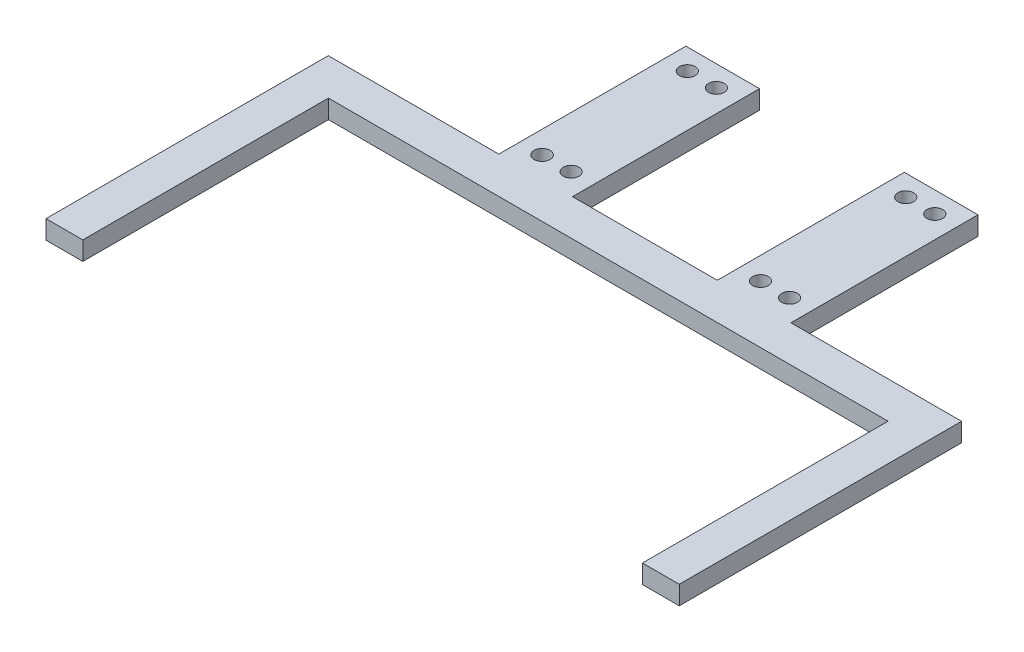
from build123d import *

# Parameters (mm, degrees)
BOSS_EXTRUDE1_DEPTH = 6.35
SKETCH3_R           = 2.713000027
SKETCH3_R_2         = 2.663
CUT_EXTRUDE1_DEPTH  = 6.35


with BuildPart() as part:
    # Sketch1 → Boss-Extrude1 (new body)
    with BuildSketch(Plane(origin=(0, 0, 0), x_dir=(1, 0, 0), z_dir=(0, 1, 0))):
        Polygon((19.294897536, -16.615040594), (19.294897536, 79.223583745), (77.210897536, 79.223583745), (77.210897536, 142.723583745), (102.210897536, 142.723583745), (102.210897536, 79.223583745), (151.378897536, 79.223583745), (151.378897536, 142.723583745), (176.378897536, 142.723583745), (176.378897536, 79.223583745), (234.294897536, 79.223583745), (234.294897536, -16.615040594), (221.794897536, -16.615040594), (221.794897536, 66.777583745), (31.794897536, 66.777583745), (31.794897536, -16.615040594), align=None)
    extrude(amount=BOSS_EXTRUDE1_DEPTH)

    # Sketch3 → Cut-Extrude1 (cut)
    with BuildSketch(Plane.XZ):
        with Locations((84.779897535, -86.323583745)):
            Circle(SKETCH3_R)
        with Locations((94.649897535, -86.323583745)):
            Circle(SKETCH3_R_2)
        with Locations((84.779897535, -135.623583745)):
            Circle(SKETCH3_R_2)
        with Locations((94.649897535, -135.623583745)):
            Circle(SKETCH3_R_2)
        with Locations((158.939897536, -86.323583745)):
            Circle(SKETCH3_R_2)
        with Locations((168.809897536, -86.323583745)):
            Circle(SKETCH3_R_2)
        with Locations((158.939897536, -135.623583745)):
            Circle(SKETCH3_R_2)
        with Locations((168.809897536, -135.623583745)):
            Circle(SKETCH3_R_2)
    extrude(amount=-CUT_EXTRUDE1_DEPTH, mode=Mode.SUBTRACT)


solid = part.part
